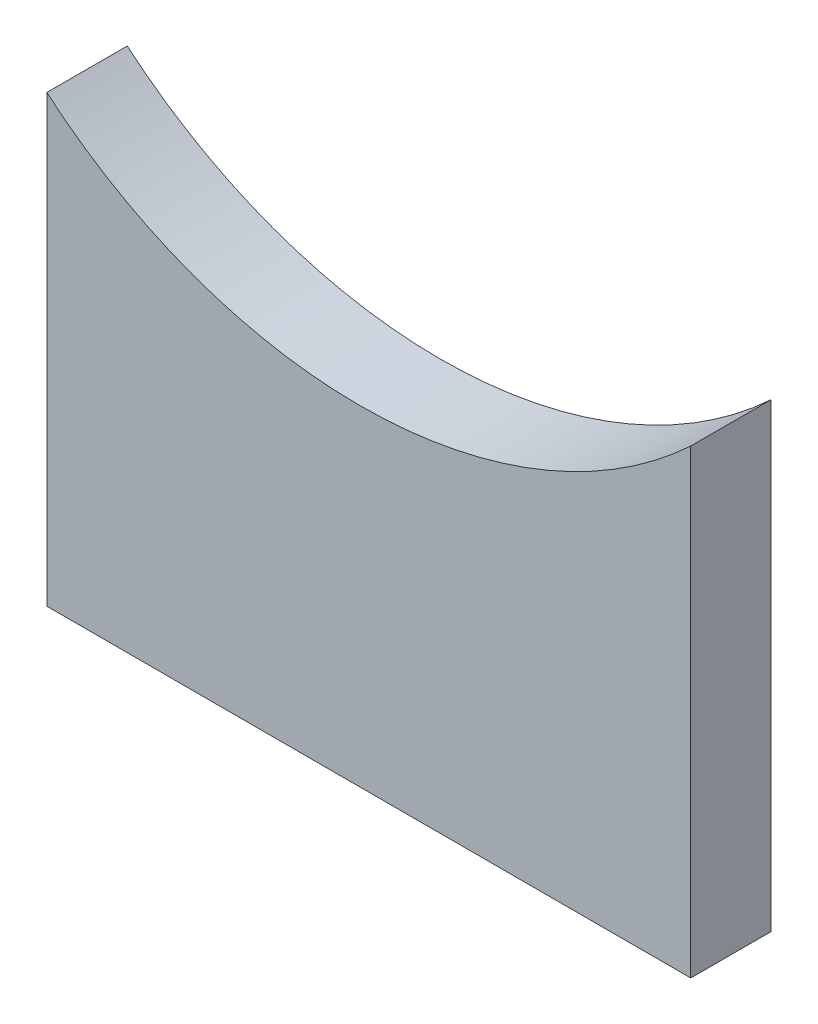
from build123d import *

# Parameters (mm, degrees)
SZKIC1_W                    = 16
SZKIC1_H                    = 31.855734842
DODANIE_WYCI_GNI_CIE1_DEPTH = 2
SZKIC2_W                    = 16
SZKIC2_H                    = 5
WYTNIJ_WYCI_GNI_CIE1_DEPTH  = 5
WYTNIJ_WYCI_GNI_CIE2_DEPTH  = 10
WYTNIJ_WYCI_GNI_CIE3_DEPTH  = 10


with BuildPart() as part:
    # Szkic1 → Dodanie-wyciągnięcie1 (new body)
    with BuildSketch(Plane.XY):
        with Locations((8, 15.927867421)):
            Rectangle(SZKIC1_W, SZKIC1_H)
    extrude(amount=DODANIE_WYCI_GNI_CIE1_DEPTH)

    # Szkic2 → Wytnij-wyciągnięcie1 (cut)
    with BuildSketch(Plane.XY.offset(2)):
        with Locations((8, 2.5)):
            Rectangle(SZKIC2_W, SZKIC2_H)
    extrude(amount=-WYTNIJ_WYCI_GNI_CIE1_DEPTH, mode=Mode.SUBTRACT)

    # Szkic6 → Wytnij-wyciągnięcie2 (cut)
    with BuildSketch(Plane(origin=(0, 0, 0), x_dir=(-1, 0, 0), z_dir=(0, 0, -1))):
        with BuildLine():
            Line((0, 31.855734842), (-16, 31.855734842))
            Line((-16, 31.855734842), (-16, 18.750886073))
            ThreePointArc((-16, 18.750886073), (-8.06030582, 15.602264045), (0, 18.427867421))
            Line((0, 18.427867421), (0, 31.855734842))
        make_face()
    extrude(amount=-WYTNIJ_WYCI_GNI_CIE2_DEPTH, mode=Mode.SUBTRACT)

    # Szkic8 → Wytnij-wyciągnięcie3 (cut)
    with BuildSketch(Plane(origin=(0, 0, 0), x_dir=(-1, 0, 0), z_dir=(0, 0, -1))):
        with BuildLine():
            Line((-16, 18.750886073), (-16, 16.446330699))
            ThreePointArc((-16, 16.446330699), (-8.074613492, 13.210416858), (0, 16.05356769))
            Line((0, 16.05356769), (0, 18.427867421))
            Line((0, 18.427867421), (-16, 18.750886073))
        make_face()
    extrude(amount=-WYTNIJ_WYCI_GNI_CIE3_DEPTH, mode=Mode.SUBTRACT)


solid = part.part
